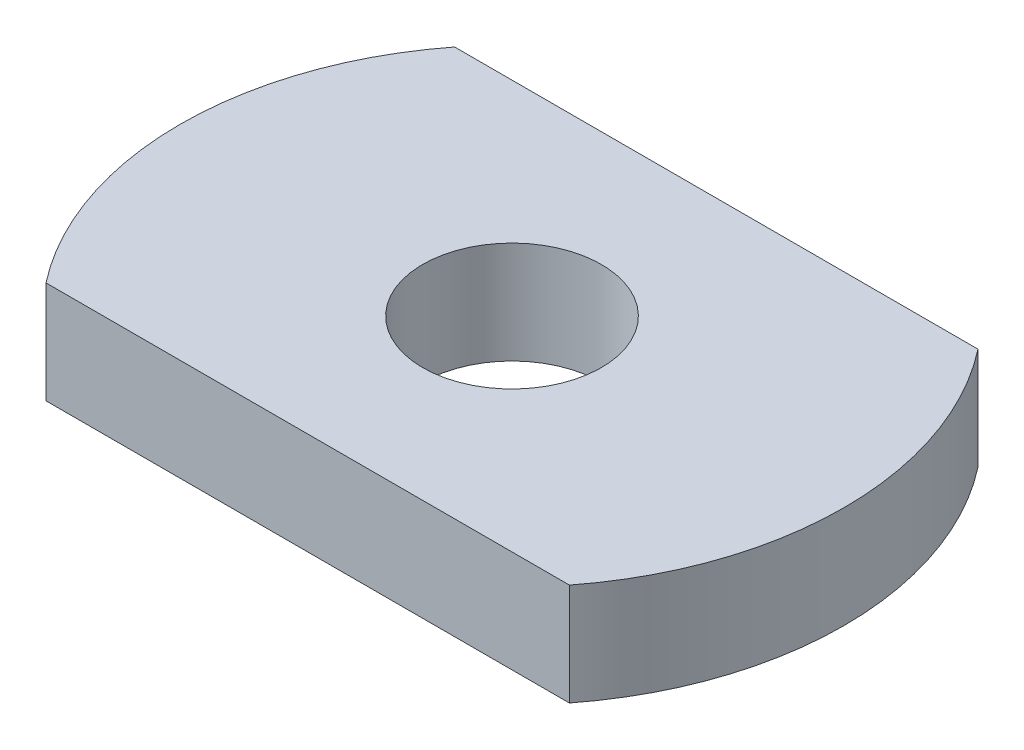
from build123d import *

# Parameters (mm, degrees)
BOSS_EXTRUDE1_DEPTH = 2


with BuildPart() as part:
    # Sketch1 → Boss-Extrude1 (new body)
    with BuildSketch(Plane(origin=(0, 0, 0), x_dir=(1, 0, 0), z_dir=(0, 1, 0))):
        with BuildLine():
            ThreePointArc((-5.123475383, 4), (-6.146242348, 2.115113473), (-6.5, 0))
            Line((-6.5, 0), (-1.75, 0))
            ThreePointArc((-1.75, 0), (-1.237436867, 1.237436867), (0, 1.75))
            Line((0, 1.75), (0, 4))
            Line((0, 4), (-5.123475383, 4))
        make_face()
        with BuildLine():
            Line((0, 4), (0, 1.75))
            ThreePointArc((0, 1.75), (1.237436867, 1.237436867), (1.75, 0))
            Line((1.75, 0), (6.5, 0))
            ThreePointArc((6.5, 0), (6.146242348, 2.115113473), (5.123475383, 4))
            Line((5.123475383, 4), (0, 4))
        make_face()
        with BuildLine():
            Line((-1.75, 0), (-6.5, 0))
            ThreePointArc((-6.5, 0), (-6.146242348, -2.115113473), (-5.123475383, -4))
            Line((-5.123475383, -4), (0, -4))
            Line((0, -4), (0, -1.75))
            ThreePointArc((0, -1.75), (-1.237436867, -1.237436867), (-1.75, 0))
        make_face()
        with BuildLine():
            Line((0, -1.75), (0, -4))
            Line((0, -4), (5.123475383, -4))
            ThreePointArc((5.123475383, -4), (6.146242348, -2.115113473), (6.5, 0))
            Line((6.5, 0), (1.75, 0))
            ThreePointArc((1.75, 0), (1.237436867, -1.237436867), (0, -1.75))
        make_face()
    extrude(amount=BOSS_EXTRUDE1_DEPTH)


solid = part.part
